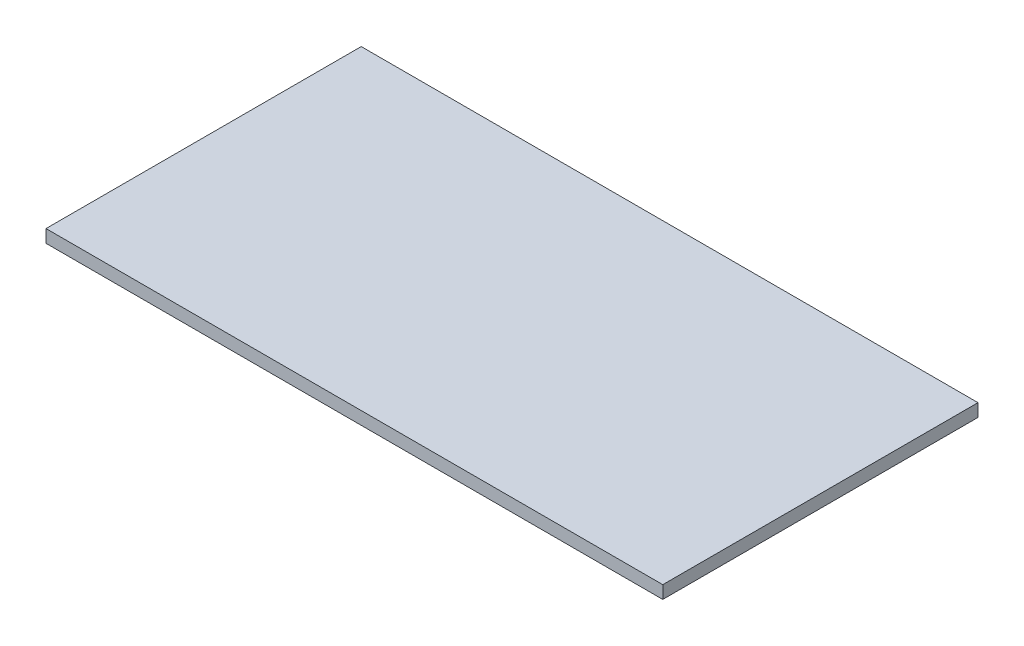
from build123d import *

# Parameters (mm, degrees)
SKETCH1_W           = 573.0875
SKETCH1_H           = 11.90625
BOSS_EXTRUDE1_DEPTH = 292.89375


with BuildPart() as part:
    # Sketch1 → Boss-Extrude1 (new body)
    with BuildSketch(Plane.XY):
        Rectangle(SKETCH1_W, SKETCH1_H)
    extrude(amount=-BOSS_EXTRUDE1_DEPTH)


solid = part.part
